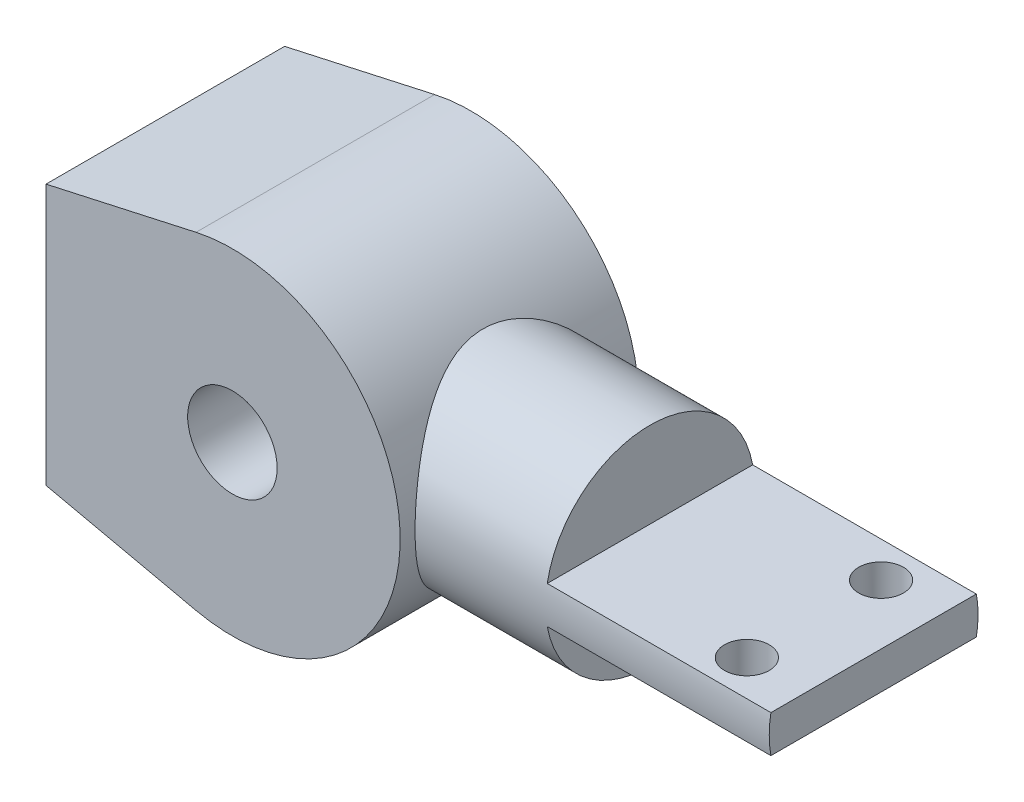
from build123d import *

# Parameters (mm, degrees)
IZIM1_R                     = 6
Y_KSEKLIK_EKSTR_ZYON1_DEPTH = 16
Y_KSEKLIK_EKSTR_ZYON2_REACH = 67
IZIM2_R                     = 14
Y_KSEKLIK_EKSTR_ZYON3_DEPTH = 30
IZIM4_R                     = 3
KES_EKSTR_ZYON1_DEPTH       = 30


with BuildPart() as part:
    # Çizim1 → Yükseklik-Ekstrüzyon1 (new body, symmetric)
    with BuildSketch(Plane.XY):
        with BuildLine():
            Line((-25, 17.5), (-25, -17.5))
            Line((-25, -17.5), (-4.873971328, -21.965755245))
            ThreePointArc((-4.873971328, -21.965755245), (22.5, 0), (-4.873971328, 21.965755245))
            Line((-4.873971328, 21.965755245), (-25, 17.5))
        make_face()
        Circle(IZIM1_R, mode=Mode.SUBTRACT)
    extrude(amount=Y_KSEKLIK_EKSTR_ZYON1_DEPTH, both=True)

    # Çizim2 → Yükseklik-Ekstrüzyon2 (add, up to next)
    with BuildSketch(Plane(origin=(40, 0, 0), x_dir=(0, 0, -1), z_dir=(1, 0, 0)), mode=Mode.PRIVATE) as y_kseklik_ekstr_zyon2_sk1:
        Circle(IZIM2_R)
    y_kseklik_ekstr_zyon2_tool1 = extrude(y_kseklik_ekstr_zyon2_sk1.sketch, amount=-Y_KSEKLIK_EKSTR_ZYON2_REACH, mode=Mode.PRIVATE) - part.part
    add(y_kseklik_ekstr_zyon2_tool1.solids().sort_by_distance((40, 0, 0))[0])

    # Çizim3 → Yükseklik-Ekstrüzyon3 (add)
    with BuildSketch(Plane(origin=(40, 0, 0), x_dir=(0, 0, -1), z_dir=(1, 0, 0))):
        with BuildLine():
            ThreePointArc((-13.774977314, 2.5), (-14, 0), (-13.774977314, -2.5))
            Line((-13.774977314, -2.5), (13.774977314, -2.5))
            ThreePointArc((13.774977314, -2.5), (13.943630847, -1.255053307), (14, 0))
            ThreePointArc((14, 0), (13.943630847, 1.255053307), (13.774977314, 2.5))
            Line((13.774977314, 2.5), (-13.774977314, 2.5))
        make_face()
    extrude(amount=Y_KSEKLIK_EKSTR_ZYON3_DEPTH)

    # Çizim4 → Kes-Ekstrüzyon1 (cut)
    with BuildSketch(Plane(origin=(0, 2.5, 0), x_dir=(1, 0, 0), z_dir=(0, 1, 0))):
        with Locations((62, -9)):
            Circle(IZIM4_R)
        with Locations((62, 9)):
            Circle(IZIM4_R)
    extrude(amount=-KES_EKSTR_ZYON1_DEPTH, mode=Mode.SUBTRACT)


solid = part.part
